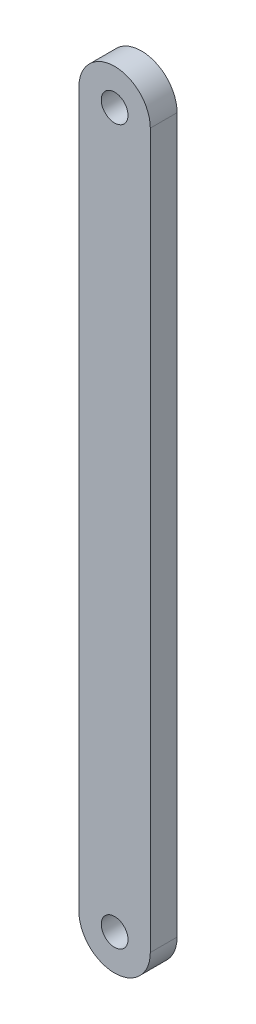
from build123d import *

# Parameters (mm, degrees)
SKETCH_2_R      = 1.5
EXTRUDE_1_DEPTH = 3


with BuildPart() as part:
    # 草圖2 → 填料-伸長1 (new body)
    with BuildSketch(Plane.XY):
        with BuildLine():
            Line((2198.740145456, 1572.08621907), (2198.740145456, 1577.10008841))
            ThreePointArc((2198.740145456, 1577.10008841), (2194.740145456, 1581.10008841), (2190.740145456, 1577.10008841))
            Line((2190.740145456, 1577.10008841), (2190.740145457, 1572.15435767))
            Line((2190.740145457, 1572.15435767), (2190.740145457, 1571.15435767))
            Line((2190.740145457, 1571.15435767), (2190.740145456, 1541.250580548))
            Line((2190.740145456, 1541.250580548), (2190.740145456, 1540.250580548))
            Line((2190.740145456, 1540.250580548), (2190.740145456, 1516.623912375))
            Line((2190.740145456, 1516.623912375), (2190.740145456, 1515.623912375))
            Line((2190.740145456, 1515.623912375), (2190.740145455, 1497.10018841))
            ThreePointArc((2190.740145455, 1497.10018841), (2194.740095455, 1493.100088408), (2198.740145455, 1497.100088412))
            Line((2198.740145455, 1497.100088412), (2198.740145456, 1515.966387039))
            Line((2198.740145456, 1515.966387039), (2198.740145456, 1516.966387039))
            Line((2198.740145456, 1516.966387039), (2198.740145456, 1541.60008841))
            Line((2198.740145456, 1541.60008841), (2198.740145456, 1542.60008841))
            Line((2198.740145456, 1542.60008841), (2198.740145456, 1571.08621907))
            Line((2198.740145456, 1571.08621907), (2198.740145456, 1572.08621907))
        make_face()
        with Locations((2194.740145455, 1497.100088409)):
            Circle(SKETCH_2_R, mode=Mode.SUBTRACT)
        with Locations((2194.740195453, 1577.100138407)):
            Circle(SKETCH_2_R, mode=Mode.SUBTRACT)
    extrude(amount=EXTRUDE_1_DEPTH)


solid = part.part
